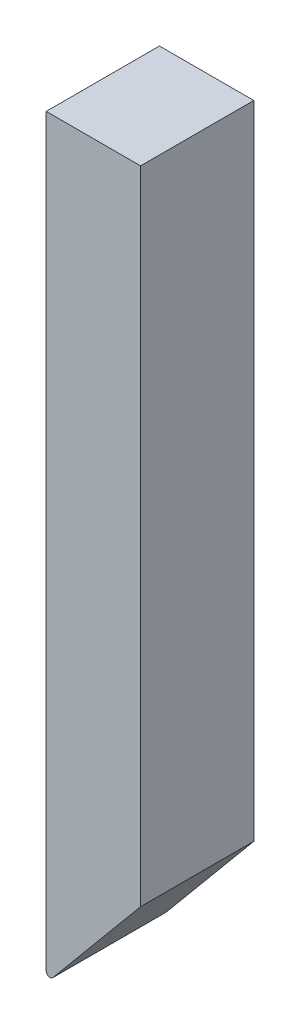
from build123d import *

# Parameters (mm, degrees)
BOSS_EXTRUDE1_DEPTH = 3
FILLET2_R           = 0.1


with BuildPart() as part:
    # Sketch1 → Boss-Extrude1 (new body)
    with BuildSketch(Plane.XY):
        Polygon((-1.25, -12.5), (1.25, -9.5), (1.25, 7.5), (-1.25, 7.5), align=None)
    extrude(amount=BOSS_EXTRUDE1_DEPTH)

    # Fillet2
    fillet2_edges = [part.edges().sort_by_distance(p)[0] for p in [
        (-1.25, -12.5, 1.5),
    ]]
    fillet(fillet2_edges, radius=FILLET2_R)


solid = part.part
